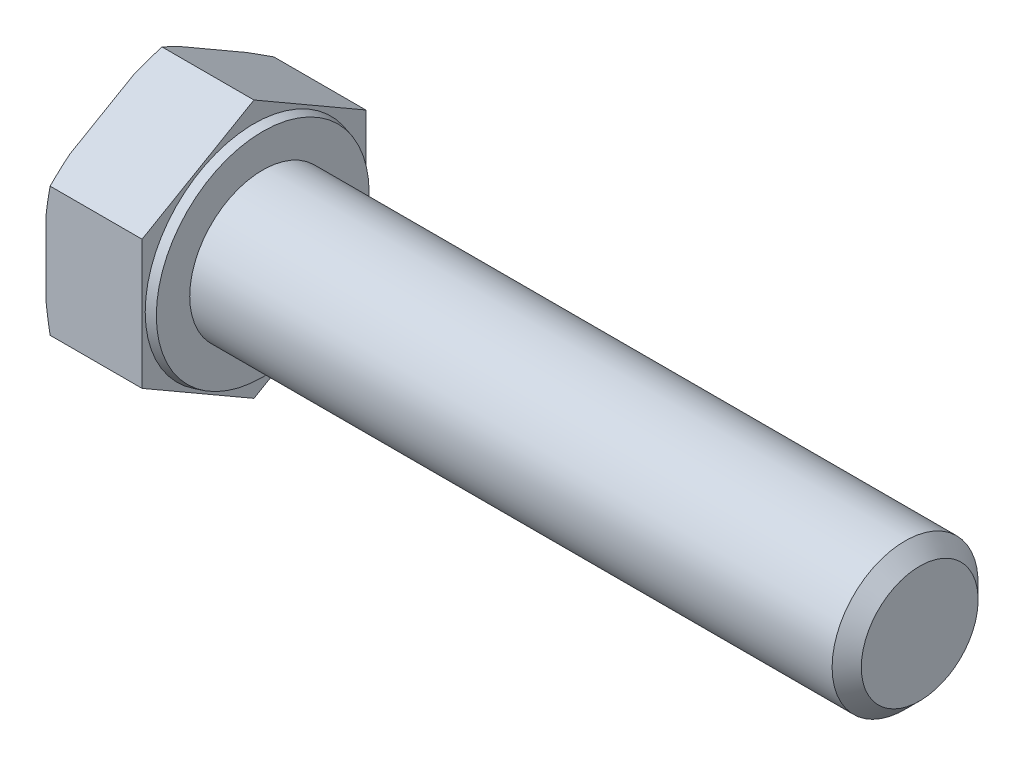
from build123d import *

# Parameters (mm, degrees)
SKETCH_2_OUTSIDE_W  = 31.274
SKETCH_2_OUTSIDE_H  = 31.274
CUT_EXTRUDE_1_DEPTH = 54.660016772
CHAMFER_1_SIZE      = 1


with BuildPart() as part:
    # Эскиз1 → Повернуть1 (revolve)
    with BuildSketch(Plane.XY, mode=Mode.PRIVATE) as revolve_1_sk:
        Polygon((-6.58, 0), (-6.58, 8.85), (0, 8.85), (0, 7.448974596), (0.6, 7.288205081), (0.6, 5), (45.6, 5), (45.6, 0), align=None)
    revolve(revolve_1_sk.sketch.rotate(Axis((-1000, 0, 0), (1, 0, 0)), 90), axis=Axis((-1000, 0, 0), (1, 0, 0)))

    # Эскиз2 outside → Вырез-Вытянуть1 (cut, through all)
    with BuildSketch(Plane.ZY.offset(6.58)):
        Rectangle(SKETCH_2_OUTSIDE_W, SKETCH_2_OUTSIDE_H)
        Polygon((0, -8.85), (7.664324823, -4.425), (7.664324823, 4.425), (0, 8.85), (-7.664324823, 4.425), (-7.664324823, -4.425), align=None, mode=Mode.SUBTRACT)
    extrude(amount=-CUT_EXTRUDE_1_DEPTH, mode=Mode.SUBTRACT)

    # Эскиз4 → Вырез-Повернуть1 (revolve, cut)
    with BuildSketch(Plane.XY):
        Polygon((-6.58, 8.075), (-6.297923068, 8.85), (-6.58, 8.85), align=None)
    revolve(axis=Axis((-1000, 0, 0), (1, 0, 0)), mode=Mode.SUBTRACT)

    # Фаска1
    chamfer_1_edges = [part.edges().sort_by_distance(p)[0] for p in [
        (45.6, 0, -5),
    ]]
    chamfer(chamfer_1_edges, length=CHAMFER_1_SIZE)


solid = part.part
